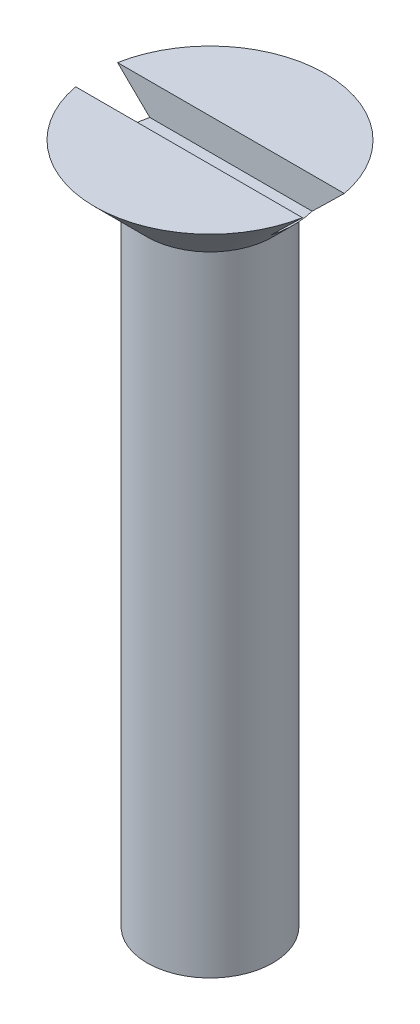
from build123d import *

# Parameters (mm, degrees)
SKETCH2_W          = 5.5
SKETCH2_H          = 1
CUT_EXTRUDE1_DEPTH = 0.75


with BuildPart() as part:
    # Sketch1 → Revolve1 (revolve)
    with BuildSketch(Plane(origin=(0, 0, 0), x_dir=(0, 0, -1), z_dir=(1, 0, 0))):
        Polygon((0, 0), (-1.5, 0), (-1.5, 15), (-2.75, 16.25), (0, 16.25), align=None)
    revolve(axis=Axis((0, 16.25, 0), (0, -1, 0)))

    # Sketch2 → Cut-Extrude1 (cut)
    with BuildSketch(Plane(origin=(0, 16.25, 0), x_dir=(1, 0, 0), z_dir=(0, 1, 0))):
        Rectangle(SKETCH2_W, SKETCH2_H)
    extrude(amount=-CUT_EXTRUDE1_DEPTH, mode=Mode.SUBTRACT)


solid = part.part
